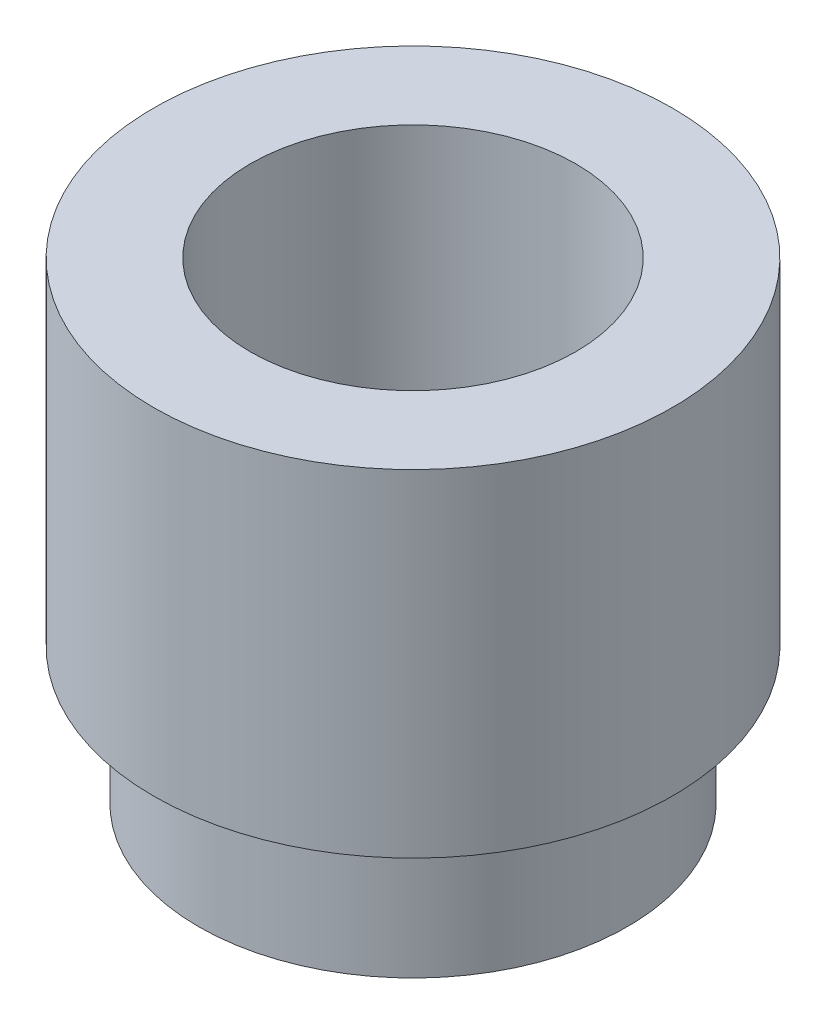
from build123d import *


with BuildPart() as part:
    # Sketch1 → Revolve1 (revolve)
    with BuildSketch(Plane.XY):
        Polygon((1.5, 4.35), (2.39, 4.35), (2.39, 1.25), (1.975, 1.25), (1.975, 0), (1.5, 0), align=None)
    revolve(axis=Axis((0, 0, 0), (0, 1, 0)))


solid = part.part
